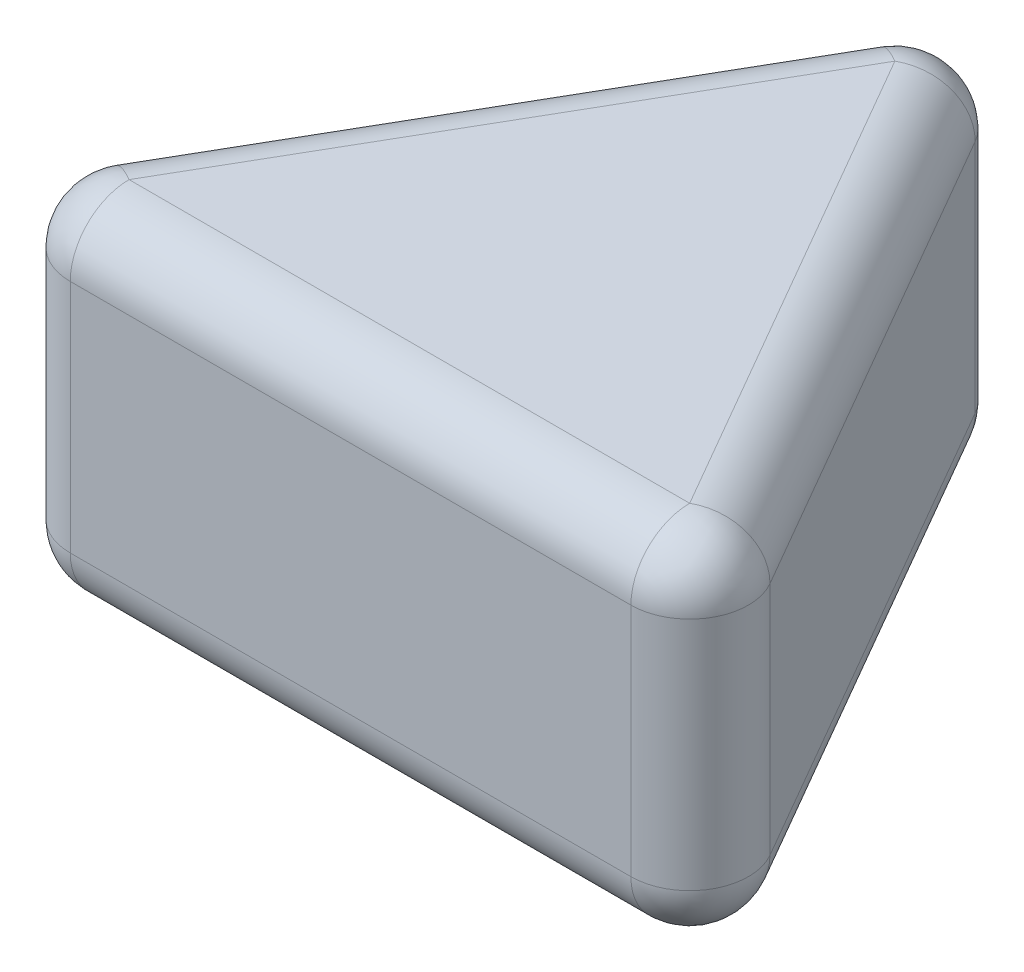
from build123d import *

# Parameters (mm, degrees)
BOSS_EXTRUDE1_DEPTH = 6
FILLET1_R           = 1


with BuildPart() as part:
    # Sketch1 → Boss-Extrude1 (new body)
    with BuildSketch(Plane(origin=(0, 0, 0), x_dir=(1, 0, 0), z_dir=(0, 1, 0))):
        Polygon((0, 0), (6.5, 11.258330249), (13, 0), align=None)
    extrude(amount=BOSS_EXTRUDE1_DEPTH)

    # Fillet1
    fillet1_edges = [part.edges().sort_by_distance(p)[0] for p in [
        (3.25, 6, -5.629165125),
        (3.25, 0, -5.629165125),
        (6.5, 6, 0),
        (9.75, 0, -5.629165125),
        (6.5, 0, 0),
        (0, 3, 0),
        (6.5, 3, -11.258330249),
        (13, 3, 0),
        (9.75, 6, -5.629165125),
    ]]
    fillet(fillet1_edges, radius=FILLET1_R)


solid = part.part
